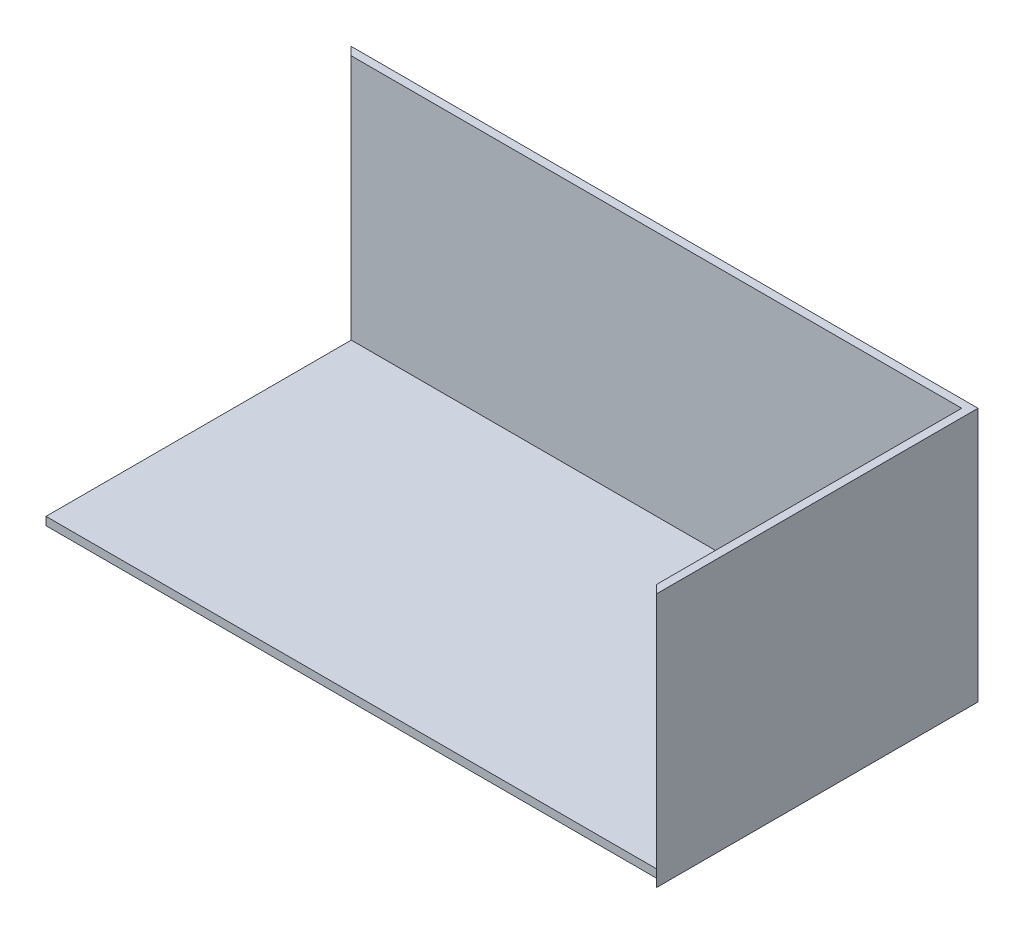
from build123d import *

# Parameters (mm, degrees)
BOSS_EXTRUDE2_DEPTH = 250
SKETCH2_8_W         = 600
SKETCH2_8_H         = 300
BOSS_EXTRUDE3_DEPTH = 8


with BuildPart() as part:
    # Sketch2 → Boss-Extrude2 (new body)
    with BuildSketch(Plane(origin=(0, 0, 0), x_dir=(1, 0, 0), z_dir=(0, 1, 0))):
        Polygon((-308, 158), (-300, 150), (300, 150), (300, -150), (308, -158), (308, 158), align=None)
    extrude(amount=BOSS_EXTRUDE2_DEPTH)

    # Sketch2_8 → Boss-Extrude3 (add)
    with BuildSketch(Plane(origin=(0, 0, 0), x_dir=(1, 0, 0), z_dir=(0, 1, 0))):
        Rectangle(SKETCH2_8_W, SKETCH2_8_H)
    extrude(amount=BOSS_EXTRUDE3_DEPTH)


solid = part.part
